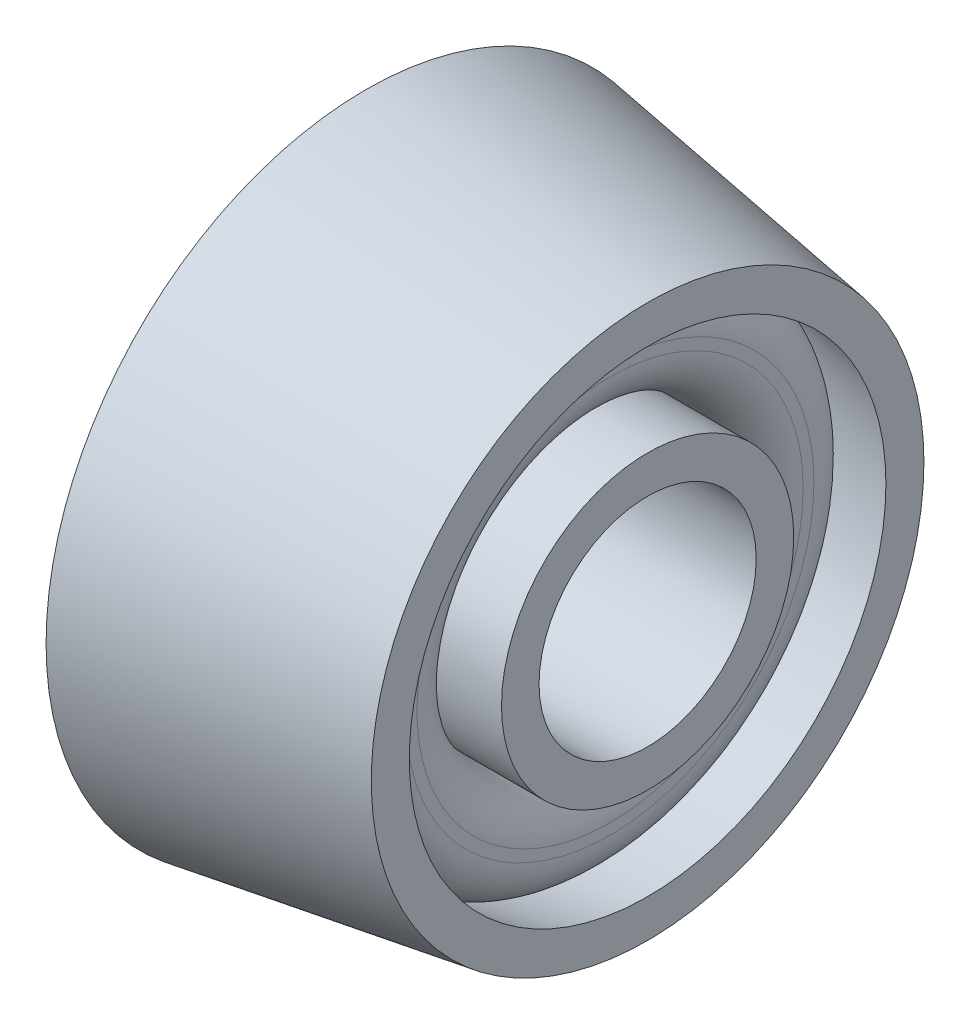
from build123d import *

# Parameters (mm, degrees)
TAPPED_HOLE_FOR_9_16_12_HELICOIL1_D = 14.68374


with BuildPart() as part:
    # Sketch1 → Revolve2 (revolve)
    with BuildSketch(Plane(origin=(0, 0, 0), x_dir=(1, 0, 0), z_dir=(0, 1, 0))):
        Polygon((882.163023054, 111.99614411), (882.163023054, 90.365625069), (901.213023054, 90.365625069), (901.213023054, 109.051426841), align=None)
    revolve(axis=Axis((1002.111866296, 0, -90.365625069), (-1, 0, 0)))

    # Tapped Hole for 9/16-12 Helicoil1 (through all)
    with Locations(Plane.ZY.offset(-882.163023054)):
        with Locations((-90.365625069, 0)):
            Hole(TAPPED_HOLE_FOR_9_16_12_HELICOIL1_D / 2)

    # Sketch5 → Cut-Revolve1 (revolve, cut)
    with BuildSketch(Plane(origin=(0, 0, 0), x_dir=(1, 0, 0), z_dir=(0, 1, 0))):
        with BuildLine():
            Line((928.636701013, 102.242153557), (928.636701013, 100.247495069))
            Line((928.636701013, 100.247495069), (895.498023054, 100.247495069))
            ThreePointArc((895.498023054, 100.247495069), (897.743087084, 101.177431039), (898.673023054, 103.422495069))
            Line((898.673023054, 103.422495069), (898.673023054, 104.151966666))
            ThreePointArc((898.673023054, 104.151966666), (897.908477535, 106.21844536), (895.983048759, 107.289700731))
            Line((895.983048759, 107.289700731), (928.636701013, 102.242153557))
        make_face()
    revolve(axis=Axis((1002.111866296, 0, -90.365625069), (-1, 0, 0)), mode=Mode.SUBTRACT)


solid = part.part
